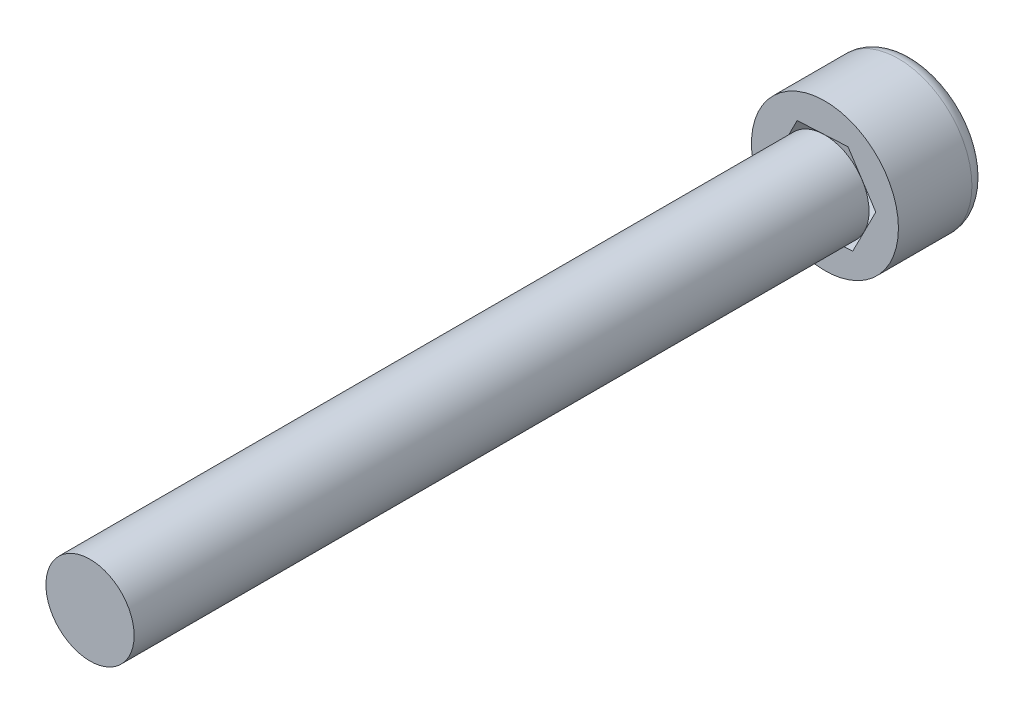
from build123d import *

# Parameters (mm, degrees)
SKETCH1_R           = 2.5
BOSS_EXTRUDE1_DEPTH = 3
SKETCH2_R           = 1.5
BOSS_EXTRUDE2_DEPTH = 25
CUT_EXTRUDE1_DEPTH  = 3
FILLET1_R           = 0.5


with BuildPart() as part:
    # Sketch1 → Boss-Extrude1 (new body)
    with BuildSketch(Plane.XY):
        Circle(SKETCH1_R)
    extrude(amount=BOSS_EXTRUDE1_DEPTH)

    # Sketch2 → Boss-Extrude2 (add)
    with BuildSketch(Plane.XY.offset(3)):
        Circle(SKETCH2_R)
    extrude(amount=BOSS_EXTRUDE2_DEPTH)

    # Sketch3 → Cut-Extrude1 (cut)
    with BuildSketch(Plane(origin=(0, 0, 0), x_dir=(-1, 0, 0), z_dir=(0, 0, -1))):
        Polygon((0.784462107, -1.544221229), (1.729565866, -0.092746502), (0.94510376, 1.451474727), (-0.784462107, 1.544221229), (-1.729565866, 0.092746502), (-0.94510376, -1.451474727), align=None)
    extrude(amount=-CUT_EXTRUDE1_DEPTH, mode=Mode.SUBTRACT)

    # Fillet1
    fillet1_edges = [part.edges().sort_by_distance(p)[0] for p in [
        (-2.5, 0, 0),
    ]]
    fillet(fillet1_edges, radius=FILLET1_R)


solid = part.part
